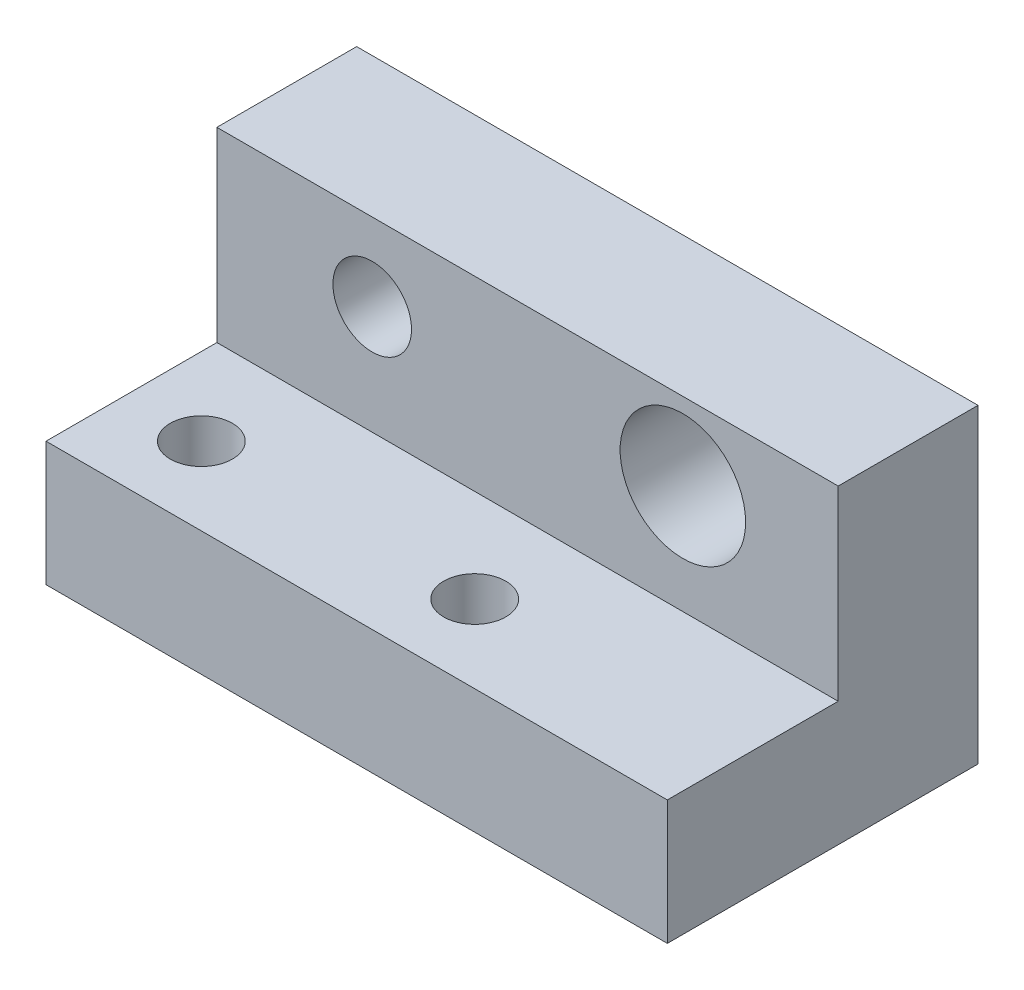
from build123d import *

# Parameters (mm, degrees)
BOSS_EXTRUDE1_DEPTH = 50.8
SKETCH4_R           = 2.54
CUT_EXTRUDE1_DEPTH  = 11.16
SKETCH5_R           = 3.2131
SKETCH5_R_2         = 5.1308
CUT_EXTRUDE2_DEPTH  = 50.8


with BuildPart() as part:
    # Sketch3 → Boss-Extrude1 (new body)
    with BuildSketch(Plane(origin=(0, 0, 0), x_dir=(0, 0, -1), z_dir=(1, 0, 0))):
        Polygon((0, 0), (25.4, 0), (25.4, 25.4), (13.97, 25.4), (13.97, 10.16), (0, 10.16), align=None)
    extrude(amount=-BOSS_EXTRUDE1_DEPTH)

    # Sketch4 → Cut-Extrude1 (cut, through all)
    with BuildSketch(Plane(origin=(0, 10.16, 0), x_dir=(1, 0, 0), z_dir=(0, 1, 0))):
        with Locations((-44.45, 6.35)):
            Circle(SKETCH4_R)
        with Locations((-22.098, 6.35)):
            Circle(SKETCH4_R)
    extrude(amount=-CUT_EXTRUDE1_DEPTH, mode=Mode.SUBTRACT)

    # Sketch5 → Cut-Extrude2 (cut)
    with BuildSketch(Plane.XY.offset(-13.97)):
        with Locations((-38.1, 19.05)):
            Circle(SKETCH5_R)
        with Locations((-12.7, 19.05)):
            Circle(SKETCH5_R_2)
    extrude(amount=-CUT_EXTRUDE2_DEPTH, mode=Mode.SUBTRACT)


solid = part.part
